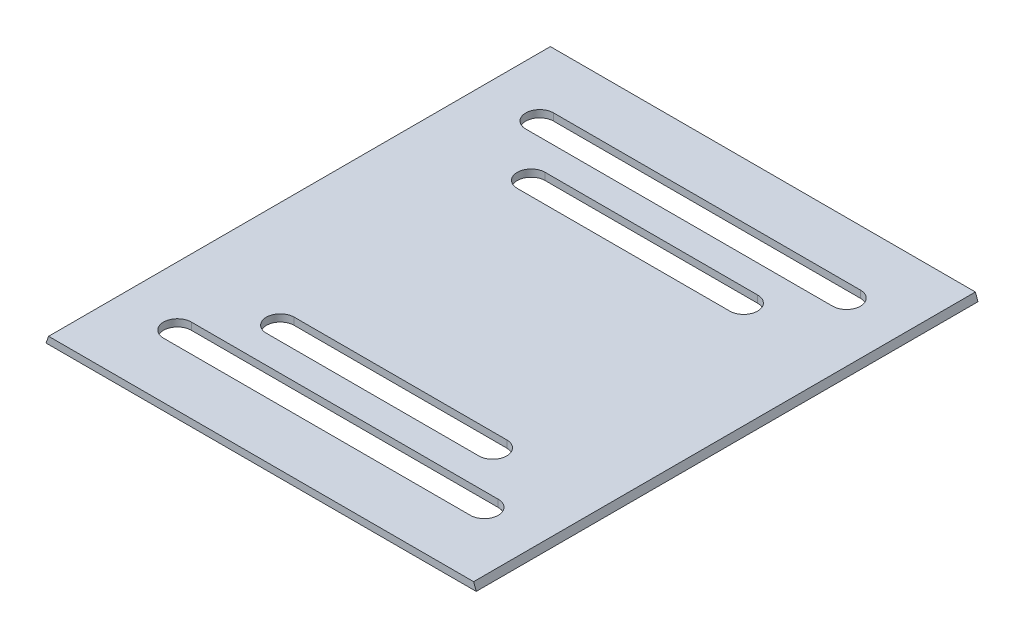
from build123d import *

# Parameters (mm, degrees)
BOSS_EXTRUDE1_DEPTH = 180
CUT_EXTRUDE1_DEPTH  = 3


with BuildPart() as part:
    # Sketch1 → Boss-Extrude1 (new body)
    with BuildSketch(Plane.XY):
        Polygon((-79.798311646, 0.218218313), (-80.70225823, -2.265354514), (73.635788627, -2.265354514), (72.731842043, 0.218218313), (72.700720755, 0.303723349), (72.541884773, 0.303723349), (-79.767190358, 0.303723349), align=None)
    extrude(amount=-BOSS_EXTRUDE1_DEPTH)

    # Sketch2 → Cut-Extrude1 (cut)
    with BuildSketch(Plane(origin=(0, 0.303723349, 0), x_dir=(1, 0, 0), z_dir=(0, 1, 0))):
        with BuildLine():
            Line((-41.65021258, 50), (34.583742977, 50))
            ThreePointArc((34.583742977, 50), (39.583742977, 45), (34.583742977, 40))
            Line((34.583742977, 40), (-41.65021258, 40))
            ThreePointArc((-41.65021258, 40), (-46.65021258, 45), (-41.65021258, 50))
        make_face()
        with BuildLine():
            Line((-56.99562327, 30.024566053), (51.503813463, 30.024566053))
            ThreePointArc((51.503813463, 30.024566053), (56.503813463, 25.024566053), (51.503813463, 20.024566053))
            Line((51.503813463, 20.024566053), (-58.570283066, 20.024566053))
            ThreePointArc((-58.570283066, 20.024566053), (-63.570283066, 25.024566053), (-58.570283066, 30.024566053))
            Line((-58.570283066, 30.024566053), (-56.99562327, 30.024566053))
        make_face()
        with BuildLine():
            Line((-56.99562327, 149.975433947), (-58.570283066, 149.975433947))
            ThreePointArc((-58.570283066, 149.975433947), (-63.570283066, 154.975433947), (-58.570283066, 159.975433947))
            Line((-58.570283066, 159.975433947), (51.503813463, 159.975433947))
            ThreePointArc((51.503813463, 159.975433947), (56.503813463, 154.975433947), (51.503813463, 149.975433947))
            Line((51.503813463, 149.975433947), (-56.99562327, 149.975433947))
        make_face()
        with BuildLine():
            Line((-41.65021258, 140), (34.583742977, 140))
            ThreePointArc((34.583742977, 140), (39.583742977, 135), (34.583742977, 130))
            Line((34.583742977, 130), (-41.65021258, 130))
            ThreePointArc((-41.65021258, 130), (-46.65021258, 135), (-41.65021258, 140))
        make_face()
    extrude(amount=-CUT_EXTRUDE1_DEPTH, mode=Mode.SUBTRACT)


solid = part.part
